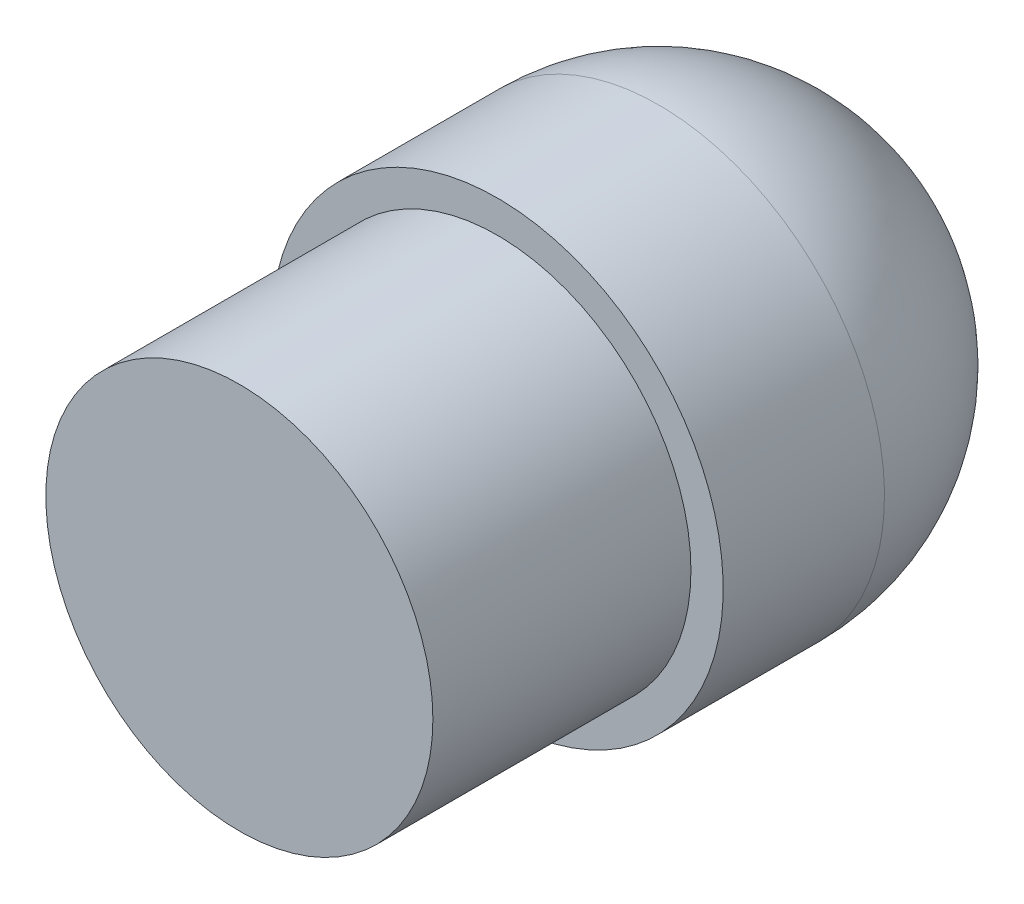
from build123d import *

# Parameters (mm, degrees)
IZIM3_R                     = 15
Y_KSEKLIK_EKSTR_ZYON1_DEPTH = 20
IZIM4_R                     = 17.5
Y_KSEKLIK_EKSTR_ZYON2_DEPTH = 12.5


with BuildPart() as part:
    # Çizim3 → Yükseklik-Ekstrüzyon1 (new body)
    with BuildSketch(Plane.XY):
        Circle(IZIM3_R)
    extrude(amount=-Y_KSEKLIK_EKSTR_ZYON1_DEPTH)

    # Çizim4 → Yükseklik-Ekstrüzyon2 (add)
    with BuildSketch(Plane(origin=(0, 0, -20), x_dir=(-1, 0, 0), z_dir=(0, 0, -1))):
        Circle(IZIM4_R)
    extrude(amount=Y_KSEKLIK_EKSTR_ZYON2_DEPTH)

    # Çizim5 → Döndür4 (revolve)
    with BuildSketch(Plane(origin=(0, 0, 0), x_dir=(0, 0, -1), z_dir=(1, 0, 0))):
        with BuildLine():
            Line((50, 0), (32.5, 0))
            Line((32.5, 0), (32.5, -17.5))
            ThreePointArc((32.5, -17.5), (44.874368671, -12.374368671), (50, 0))
        make_face()
    revolve(axis=Axis((0, 0, -32.5), (0, 0, -1)))


solid = part.part
